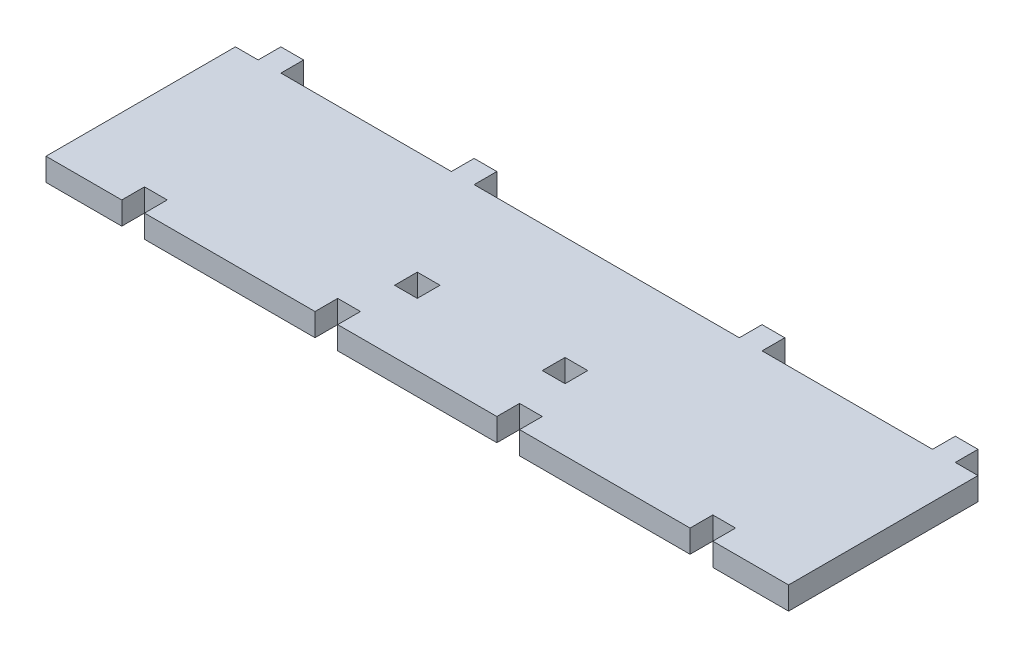
from build123d import *

# Parameters (mm, degrees)
SKETCH1_W           = 196
SKETCH1_H           = 6
BOSS_EXTRUDE1_DEPTH = 50
SKETCH2_W           = 6
SKETCH2_H           = 6
BOSS_EXTRUDE2_DEPTH = 6
SKETCH3_W           = 6
SKETCH3_H           = 6
CUT_EXTRUDE1_DEPTH  = 6
SKETCH5_W           = 6
SKETCH5_H           = 6
CUT_EXTRUDE2_DEPTH  = 6


with BuildPart() as part:
    # Sketch1 → Boss-Extrude1 (new body)
    with BuildSketch(Plane.XY):
        with Locations((0, 3)):
            Rectangle(SKETCH1_W, SKETCH1_H)
    extrude(amount=BOSS_EXTRUDE1_DEPTH)

    # Sketch2 → Boss-Extrude2 (add)
    with BuildSketch(Plane(origin=(0, 0, 0), x_dir=(-1, 0, 0), z_dir=(0, 0, -1))):
        with Locations((-89, 3)):
            Rectangle(SKETCH2_W, SKETCH2_H)
        with Locations((-38, 3)):
            Rectangle(SKETCH2_W, SKETCH2_H)
        with Locations((38, 3)):
            Rectangle(SKETCH2_W, SKETCH2_H)
        with Locations((89, 3)):
            Rectangle(SKETCH2_W, SKETCH2_H)
    extrude(amount=BOSS_EXTRUDE2_DEPTH)

    # Sketch3 → Cut-Extrude1 (cut)
    with BuildSketch(Plane(origin=(0, 6, 0), x_dir=(1, 0, 0), z_dir=(0, 1, 0))):
        with Locations((75, -47)):
            Rectangle(SKETCH3_W, SKETCH3_H)
        with Locations((24, -47)):
            Rectangle(SKETCH3_W, SKETCH3_H)
        with Locations((-24, -47)):
            Rectangle(SKETCH3_W, SKETCH3_H)
        with Locations((-75, -47)):
            Rectangle(SKETCH3_W, SKETCH3_H)
    extrude(amount=-CUT_EXTRUDE1_DEPTH, mode=Mode.SUBTRACT)

    # Sketch5 → Cut-Extrude2 (cut)
    with BuildSketch(Plane.XZ):
        with Locations((-19.5, 30.5)):
            Rectangle(SKETCH5_W, SKETCH5_H)
        with Locations((19.5, 30.5)):
            Rectangle(SKETCH5_W, SKETCH5_H)
    extrude(amount=-CUT_EXTRUDE2_DEPTH, mode=Mode.SUBTRACT)


solid = part.part
